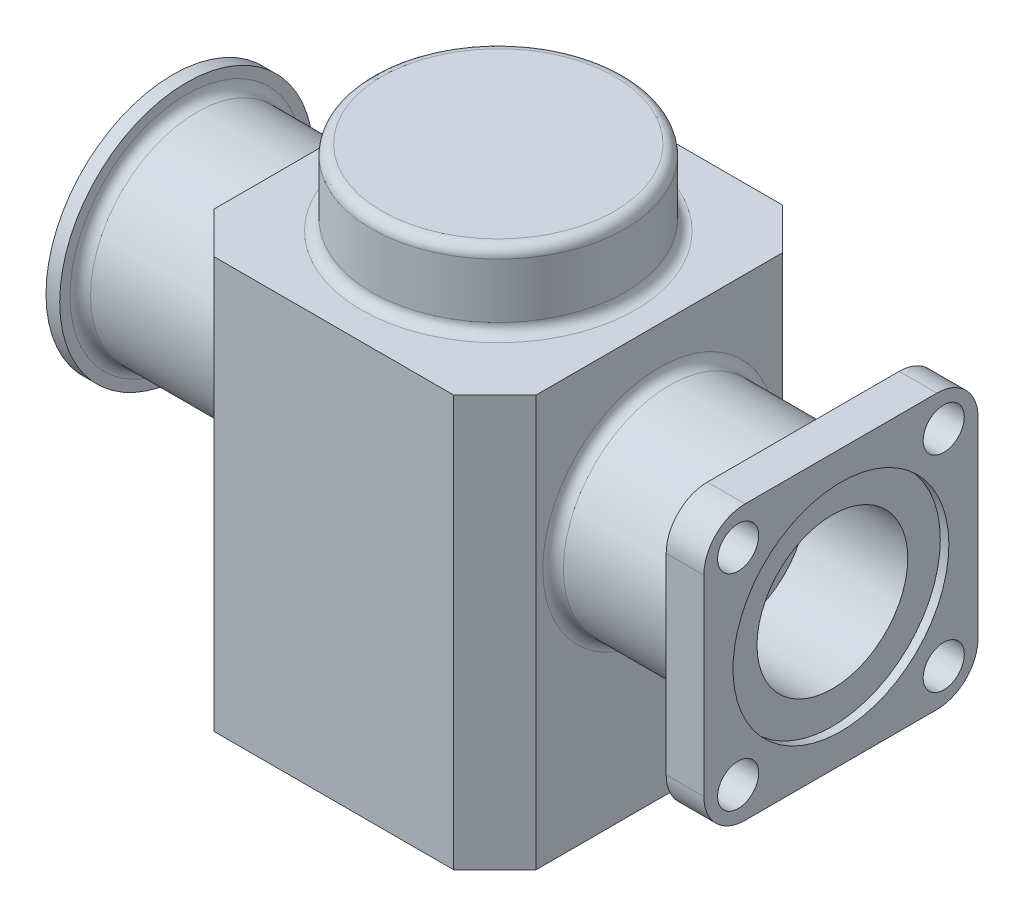
from build123d import *

# Parameters (mm, degrees)
EXTRUDE_1_DEPTH      = 22
EXTRUDE_1_DEPTH_BACK = 120
SKETCH_1_W           = 94
SKETCH_1_H           = 96
CUT_EXTRUDE_1_REACH  = 139.525
SKETCH_1_3_W         = 94
SKETCH_1_3_H         = 96
SKETCH_1_3_R         = 37
SKETCH_3_R           = 15
CUT_EXTRUDE_2_DEPTH  = 188.616630393
EXTRUDE_START        = 11
SKETCH_4_W           = 80
SKETCH_4_H           = 80
SKETCH_4_R           = 6
SKETCH_4_R_2         = 22
EXTRUDE_2_DEPTH      = 11
SKETCH_5_R           = 31.5
CUT_EXTRUDE_3_DEPTH  = 2.5
FILLET_1_R           = 3
FILLET_2_R           = 12
CHAMFER_1_SIZE       = 12
CHAMFER_2_SIZE       = 1.3


with BuildPart() as part:
    # Эскиз1 → Бобышка-Вытянуть1 (new, two sides: drawn at the far end of the back side and taken through both)
    with BuildSketch(Plane(origin=(0, 0, 0), x_dir=(1, 0, 0), z_dir=(0, 1, 0)).offset(-EXTRUDE_1_DEPTH_BACK)):
        Rectangle(SKETCH_1_W, SKETCH_1_H)
    extrude(amount=EXTRUDE_1_DEPTH + EXTRUDE_1_DEPTH_BACK)

    # Эскиз1<3> → Вырез-Вытянуть1 (cut, up to next)
    with BuildSketch(Plane(origin=(0, 0, 0), x_dir=(1, 0, 0), z_dir=(0, 1, 0)), mode=Mode.PRIVATE) as cut_extrude_1_sk1:
        Rectangle(SKETCH_1_3_W, SKETCH_1_3_H)
        Circle(SKETCH_1_3_R, mode=Mode.SUBTRACT)
    cut_extrude_1_tool1 = extrude(cut_extrude_1_sk1.sketch, amount=CUT_EXTRUDE_1_REACH, mode=Mode.PRIVATE) & part.part
    add(cut_extrude_1_tool1.solids().sort_by_distance((-45.656423, 0, 0))[0], mode=Mode.SUBTRACT)

    # Эскиз2 → Повернуть1 (revolve)
    with BuildSketch(Plane.XY):
        Polygon((89, -14), (-91, -14), (-91, -8), (-95, -8), (-95, -23.5), (-65, -23.5), (-65, -21), (-56, -21), (-56, -30), (68, -30), (68, -23), (89, -23), align=None)
    revolve(axis=Axis((-47, -45, 0), (1, 0, 0)))

    # Эскиз3 → Вырез-Вытянуть2 (cut, through all)
    with BuildSketch(Plane.ZY.offset(47)):
        with Locations((0, -45)):
            Circle(SKETCH_3_R)
    extrude(amount=-CUT_EXTRUDE_2_DEPTH, mode=Mode.SUBTRACT)

    # Эскиз4 → Бобышка-Вытянуть2 (add)
    with BuildSketch(Plane(origin=(89, 0, 0), x_dir=(0, 0, -1), z_dir=(1, 0, 0)).offset(EXTRUDE_START)):
        with Locations((0, -45)):
            Rectangle(SKETCH_4_W, SKETCH_4_H)
        with Locations((-30, -15)):
            Circle(SKETCH_4_R, mode=Mode.SUBTRACT)
        with Locations((30, -15)):
            Circle(SKETCH_4_R, mode=Mode.SUBTRACT)
        with Locations((30, -75)):
            Circle(SKETCH_4_R, mode=Mode.SUBTRACT)
        with Locations((-30, -75)):
            Circle(SKETCH_4_R, mode=Mode.SUBTRACT)
        with Locations((0, -45)):
            Circle(SKETCH_4_R_2, mode=Mode.SUBTRACT)
    extrude(amount=-EXTRUDE_2_DEPTH)

    # Эскиз5 → Вырез-Вытянуть3 (cut)
    with BuildSketch(Plane(origin=(100, 0, 0), x_dir=(0, 0, -1), z_dir=(1, 0, 0))):
        with Locations((0, -45)):
            Circle(SKETCH_5_R)
    extrude(amount=-CUT_EXTRUDE_3_DEPTH, mode=Mode.SUBTRACT)

    # Эскиз6 → Вырез-Повернуть2 (revolve, cut)
    with BuildSketch(Plane.XY):
        Polygon((0, -120), (0, 6), (17.326604958, 6), (28.5, -85), (32, -85), (32, -102), (29.5, -102), (29.5, -120), align=None)
    revolve(axis=Axis((0, -120, 0), (0, 1, 0)), mode=Mode.SUBTRACT)

    # Скругление1
    fillet_1_edges = [part.edges().sort_by_distance(p)[0] for p in [
        (-91, -76, 0),
        (89, -76, 0),
        (-37, 0, 0),
        (-37, 22, 0),
        (47, -76, 0),
        (-47, -76, 0),
    ]]
    fillet(fillet_1_edges, radius=FILLET_1_R)

    # Скругление2
    fillet_2_edges = [part.edges().sort_by_distance(p)[0] for p in [
        (94.5, -5, -40),
        (94.5, -5, 40),
        (94.5, -85, 40),
        (94.5, -85, -40),
    ]]
    fillet(fillet_2_edges, radius=FILLET_2_R)

    # Фаска1
    chamfer_1_edges = [part.edges().sort_by_distance(p)[0] for p in [
        (47, -60, -48),
        (47, -60, 48),
        (-47, -60, 48),
        (-47, -60, -48),
    ]]
    chamfer(chamfer_1_edges, length=CHAMFER_1_SIZE)

    # Фаска2
    chamfer_2_edges = [part.edges().sort_by_distance(p)[0] for p in [
        (-29.5, -120, 0),
        (-95, -66.5, 0),
    ]]
    chamfer(chamfer_2_edges, length=CHAMFER_2_SIZE)


solid = part.part
